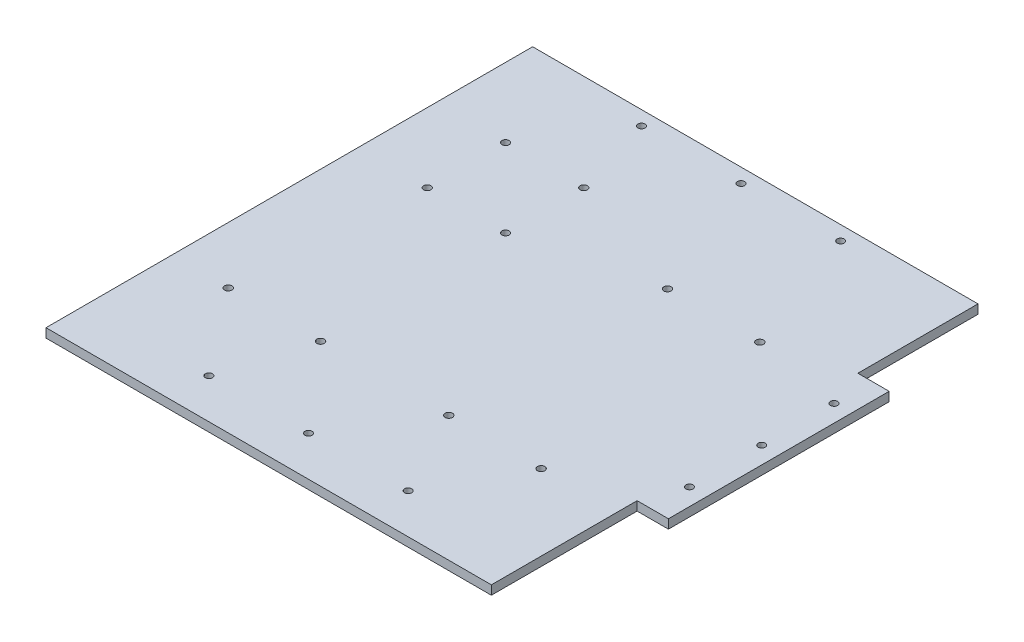
from build123d import *

# Parameters (mm, degrees)
SKETCH1_W           = 313
SKETCH1_H           = 342
BOSS_EXTRUDE1_DEPTH = 6.35
SKETCH3_W           = 22
SKETCH3_H           = 155.14040353
SKETCH3_R           = 2.5
BOSS_EXTRUDE2_DEPTH = 6.35
SKETCH2_R           = 2.5
CUT_EXTRUDE1_DEPTH  = 7.35
SKETCH4_R           = 2.6
SKETCH4_R_2         = 2.55
CUT_EXTRUDE2_DEPTH  = 7.35


with BuildPart() as part:
    # Sketch1 → Boss-Extrude1 (new body)
    with BuildSketch(Plane(origin=(0, 0, 0), x_dir=(1, 0, 0), z_dir=(0, 1, 0))):
        Rectangle(SKETCH1_W, SKETCH1_H)
    extrude(amount=-BOSS_EXTRUDE1_DEPTH)

    # Sketch3 → Boss-Extrude2 (add)
    with BuildSketch(Plane(origin=(0, 0, 0), x_dir=(1, 0, 0), z_dir=(0, 1, 0))):
        with Locations((167.5, 9)):
            Rectangle(SKETCH3_W, SKETCH3_H)
        with Locations((166.5, 9)):
            Circle(SKETCH3_R, mode=Mode.SUBTRACT)
        with Locations((166.5, -41.8)):
            Circle(SKETCH3_R, mode=Mode.SUBTRACT)
        with Locations((166.5, 59.8)):
            Circle(SKETCH3_R, mode=Mode.SUBTRACT)
    extrude(amount=-BOSS_EXTRUDE2_DEPTH)

    # Sketch2 → Cut-Extrude1 (cut, through all)
    with BuildSketch(Plane(origin=(0, 0, 0), x_dir=(1, 0, 0), z_dir=(0, 1, 0))):
        with Locations((0, -143)):
            Circle(SKETCH2_R)
        with Locations((-70, -143)):
            Circle(SKETCH2_R)
        with Locations((70, -143)):
            Circle(SKETCH2_R)
        with Locations((-70, 161)):
            Circle(SKETCH2_R)
        with Locations((0, 161)):
            Circle(SKETCH2_R)
        with Locations((70, 161)):
            Circle(SKETCH2_R)
    extrude(amount=-CUT_EXTRUDE1_DEPTH, mode=Mode.SUBTRACT)

    # Sketch4 → Cut-Extrude2 (cut, through all)
    with BuildSketch(Plane(origin=(0, 0, 0), x_dir=(1, 0, 0), z_dir=(0, 1, 0))):
        with Locations((103.249710043, -82.783250091)):
            Circle(SKETCH4_R)
        with Locations((38.349710043, -82.783250091)):
            Circle(SKETCH4_R)
        with Locations((-51.750289957, -82.783250091)):
            Circle(SKETCH4_R)
        with Locations((-116.650289957, -82.783250091)):
            Circle(SKETCH4_R)
        with Locations((103.156346537, 71.010318364)):
            Circle(SKETCH4_R)
        with Locations((38.256346537, 71.010318364)):
            Circle(SKETCH4_R)
        with Locations((-52.687463488, 48.130966948)):
            Circle(SKETCH4_R_2)
        with Locations((-107.687463488, 48.130966948)):
            Circle(SKETCH4_R_2)
        with Locations((-52.687463488, 103.130966948)):
            Circle(SKETCH4_R_2)
        with Locations((-107.687463488, 103.130966948)):
            Circle(SKETCH4_R_2)
    extrude(amount=-CUT_EXTRUDE2_DEPTH, mode=Mode.SUBTRACT)


solid = part.part
